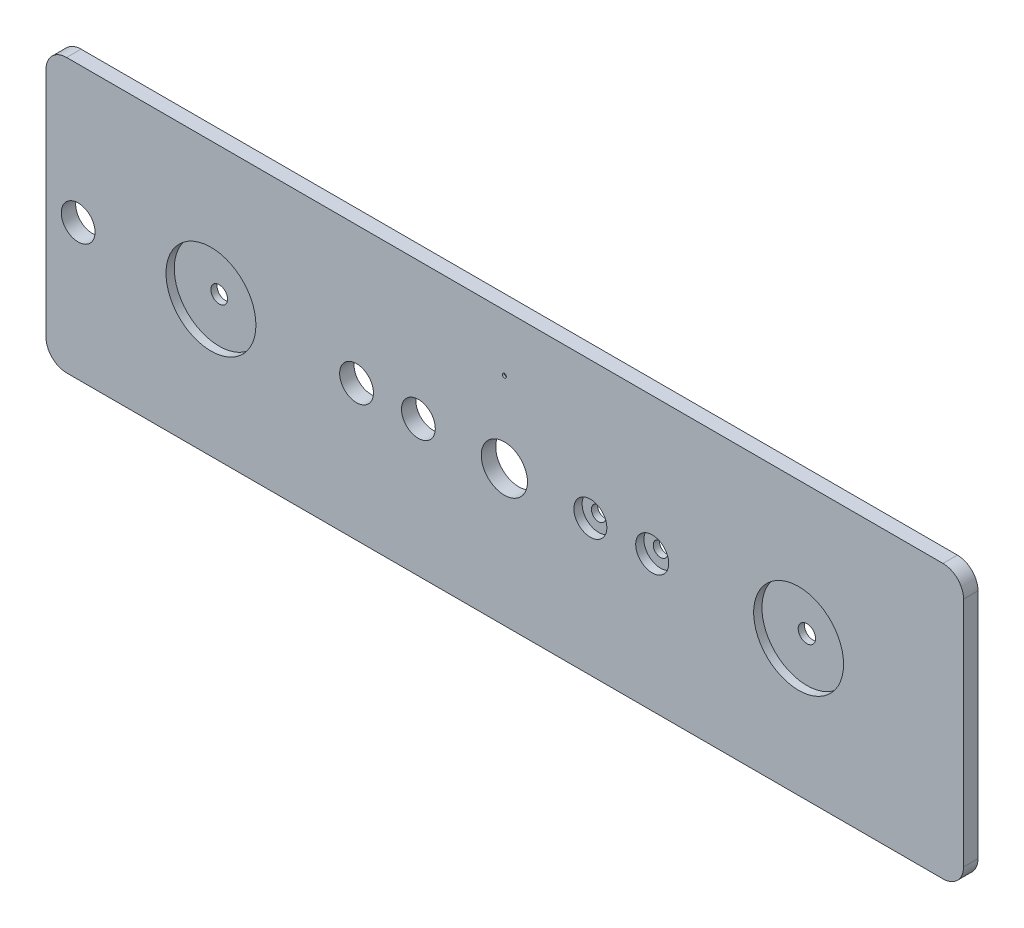
from build123d import *

# Parameters (mm, degrees)
SKETCH_1_R            = 1
SKETCH_1_R_2          = 11.2
SKETCH_1_R_3          = 4.05
SKETCH_1_R_4          = 3.5
SKETCH_1_R_5          = 8.2
SKETCH_1_R_6          = 4.2
EXTRUDE_1_DEPTH       = 7
SKETCH_6_R            = 21.8
SKETCH_6_R_2          = 8
CUT_EXTRUDE_3_DEPTH   = 4
SKETCH_7_R            = 3
CUT_EXTRUDE_4_DEPTH   = 6
SKETCH_13_R           = 1.75
CUT_EXTRUDE_4_2_DEPTH = 5


with BuildPart() as part:
    # Эскиз1 → Бобышка-Вытянуть1 (new body)
    with BuildSketch(Plane.XY):
        with BuildLine():
            Line((10, 0), (435, 0))
            ThreePointArc((435, 0), (442.071067812, 2.928932188), (445, 10))
            Line((445, 10), (445, 122.5))
            ThreePointArc((445, 122.5), (442.071067812, 129.571067812), (435, 132.5))
            Line((435, 132.5), (10, 132.5))
            ThreePointArc((10, 132.5), (2.928932188, 129.571067812), (0, 122.5))
            Line((0, 122.5), (0, 10))
            ThreePointArc((0, 10), (2.928932188, 2.928932188), (10, 0))
        make_face()
        with Locations((222.3, 105)):
            Circle(SKETCH_1_R, mode=Mode.SUBTRACT)
        with Locations((222.3, 66)):
            Circle(SKETCH_1_R_2, mode=Mode.SUBTRACT)
        with Locations((80, 66)):
            Circle(SKETCH_1_R_3, mode=Mode.SUBTRACT)
        with Locations((264, 66)):
            Circle(SKETCH_1_R_4, mode=Mode.SUBTRACT)
        with Locations((294, 66)):
            Circle(SKETCH_1_R_4, mode=Mode.SUBTRACT)
        with Locations((180.6, 66)):
            Circle(SKETCH_1_R_5, mode=Mode.SUBTRACT)
        with Locations((365, 66)):
            Circle(SKETCH_1_R_6, mode=Mode.SUBTRACT)
        with Locations((15.6, 66)):
            Circle(SKETCH_1_R_5, mode=Mode.SUBTRACT)
        with Locations((150.6, 66)):
            Circle(SKETCH_1_R_5, mode=Mode.SUBTRACT)
    extrude(amount=EXTRUDE_1_DEPTH)

    # Эскиз6 → Вырез-Вытянуть3 (cut)
    with BuildSketch(Plane.XY.offset(7)):
        with Locations((80, 66)):
            Circle(SKETCH_6_R)
        with Locations((365, 66)):
            Circle(SKETCH_6_R)
        with Locations((264, 66)):
            Circle(SKETCH_6_R_2)
        with Locations((294, 66)):
            Circle(SKETCH_6_R_2)
    extrude(amount=-CUT_EXTRUDE_3_DEPTH, mode=Mode.SUBTRACT)

    # Эскиз7 → Cut-Extrude 4 (cut)
    with BuildSketch(Plane(origin=(0, 0, 0), x_dir=(-1, 0, 0), z_dir=(0, 0, -1))):
        with Locations((-222.3, 105)):
            Circle(SKETCH_7_R)
    extrude(amount=-CUT_EXTRUDE_4_DEPTH, mode=Mode.SUBTRACT)

    # Эскиз13 → Cut-Extrude 4 2 (cut)
    with BuildSketch(Plane(origin=(0, 0, 0), x_dir=(-1, 0, 0), z_dir=(0, 0, -1))):
        with Locations((-17, 118.4)):
            Circle(SKETCH_13_R)
        with Locations((-17, 14.1)):
            Circle(SKETCH_13_R)
        with Locations((-428, 14.1)):
            Circle(SKETCH_13_R)
        with Locations((-428, 118.4)):
            Circle(SKETCH_13_R)
    extrude(amount=-CUT_EXTRUDE_4_2_DEPTH, mode=Mode.SUBTRACT)


solid = part.part
